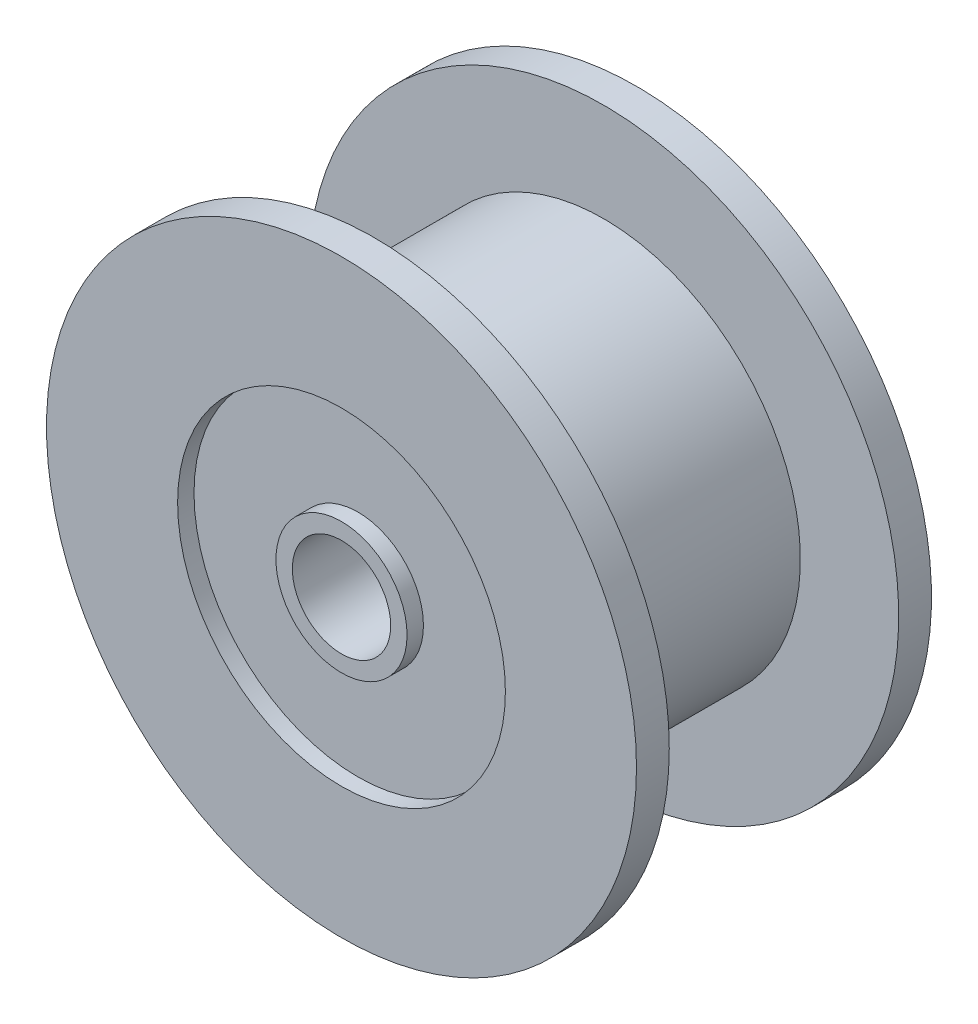
from build123d import *

# Parameters (mm, degrees)
SKETCH_1_R          = 6
EXTRUDE_1_DEPTH     = 7
SKETCH_2_R          = 9
EXTRUDE_2_DEPTH     = 1
SKETCH_3_R          = 9
EXTRUDE_3_DEPTH     = 1
SKETCH_4_R          = 1.5
CUT_EXTRUDE_2_DEPTH = 11
SKETCH_5_R          = 5
SKETCH_5_R_2        = 2
CUT_EXTRUDE_3_DEPTH = 0.5
SKETCH_6_R          = 5
SKETCH_6_R_2        = 2
CUT_EXTRUDE_4_DEPTH = 0.5


with BuildPart() as part:
    # 草图1 → 凸台-拉伸1 (new body)
    with BuildSketch(Plane.XY):
        Circle(SKETCH_1_R)
    extrude(amount=EXTRUDE_1_DEPTH)

    # 草图2 → 凸台-拉伸2 (add)
    with BuildSketch(Plane.XY.offset(7)):
        Circle(SKETCH_2_R)
    extrude(amount=EXTRUDE_2_DEPTH)

    # 草图3 → 凸台-拉伸3 (add)
    with BuildSketch(Plane(origin=(0, 0, 0), x_dir=(-1, 0, 0), z_dir=(0, 0, -1))):
        Circle(SKETCH_3_R)
    extrude(amount=EXTRUDE_3_DEPTH)

    # 草图4 → 切除-拉伸2 (cut)
    with BuildSketch(Plane.XY.offset(8)):
        Circle(SKETCH_4_R)
    extrude(amount=-CUT_EXTRUDE_2_DEPTH, mode=Mode.SUBTRACT)

    # 草图5 → 切除-拉伸3 (cut)
    with BuildSketch(Plane(origin=(0, 0, -1), x_dir=(-1, 0, 0), z_dir=(0, 0, -1))):
        Circle(SKETCH_5_R)
        Circle(SKETCH_5_R_2, mode=Mode.SUBTRACT)
    extrude(amount=-CUT_EXTRUDE_3_DEPTH, mode=Mode.SUBTRACT)

    # 草图6 → 切除-拉伸4 (cut)
    with BuildSketch(Plane.XY.offset(8)):
        Circle(SKETCH_6_R)
        Circle(SKETCH_6_R_2, mode=Mode.SUBTRACT)
    extrude(amount=-CUT_EXTRUDE_4_DEPTH, mode=Mode.SUBTRACT)


solid = part.part
